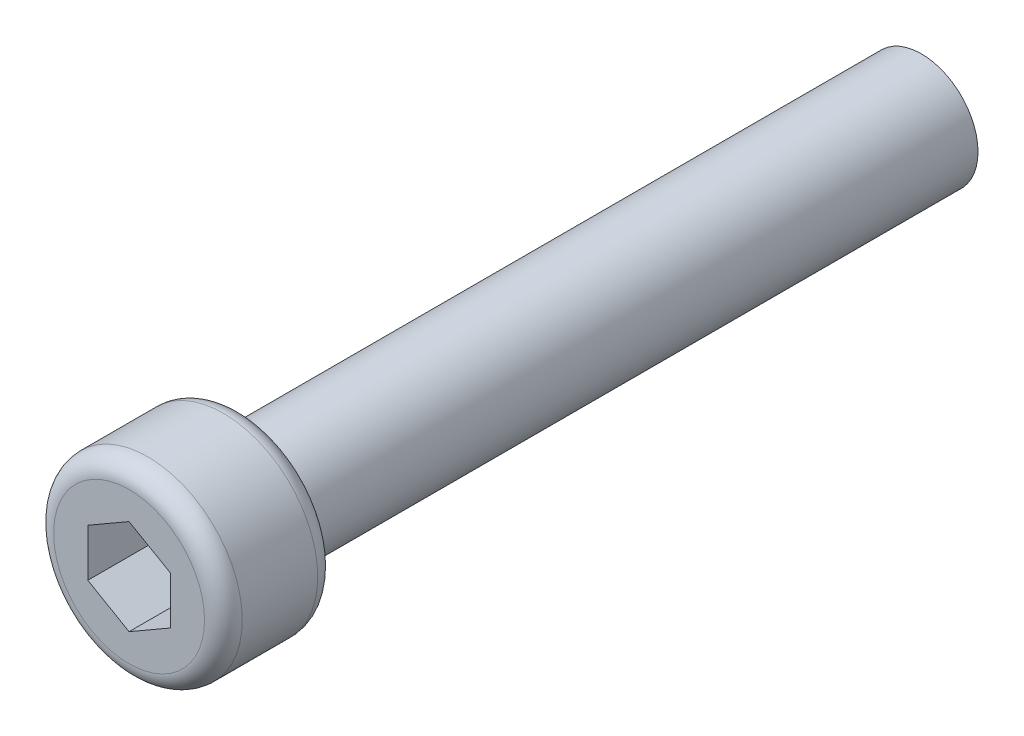
from build123d import *

# Parameters (mm, degrees)
SKETCH1_R           = 1.5
BOSS_EXTRUDE1_DEPTH = 18
SKETCH2_R           = 2.5
BOSS_EXTRUDE2_DEPTH = 3
FILLET1_R           = 0.5
CUT_EXTRUDE1_DEPTH  = 2


with BuildPart() as part:
    # Sketch1 → Boss-Extrude1 (new body)
    with BuildSketch(Plane.XY):
        with Locations((0, 1.584180911)):
            Circle(SKETCH1_R)
    extrude(amount=-BOSS_EXTRUDE1_DEPTH)

    # Sketch2 → Boss-Extrude2 (add)
    with BuildSketch(Plane.XY):
        with Locations((0, 1.584180911)):
            Circle(SKETCH2_R)
    extrude(amount=BOSS_EXTRUDE2_DEPTH)

    # Fillet1
    fillet1_edges = [part.edges().sort_by_distance(p)[0] for p in [
        (-2.5, 1.584180911, 0),
        (-2.5, 1.584180911, 3),
    ]]
    fillet(fillet1_edges, radius=FILLET1_R)

    # Sketch3 → Cut-Extrude1 (cut)
    with BuildSketch(Plane.XY.offset(3)):
        Polygon((0, 0.320652174), (1.094247985, 0.952416543), (1.094247985, 2.21594528), (0, 2.847709649), (-1.094247985, 2.21594528), (-1.094247985, 0.952416543), align=None)
    extrude(amount=-CUT_EXTRUDE1_DEPTH, mode=Mode.SUBTRACT)


solid = part.part
